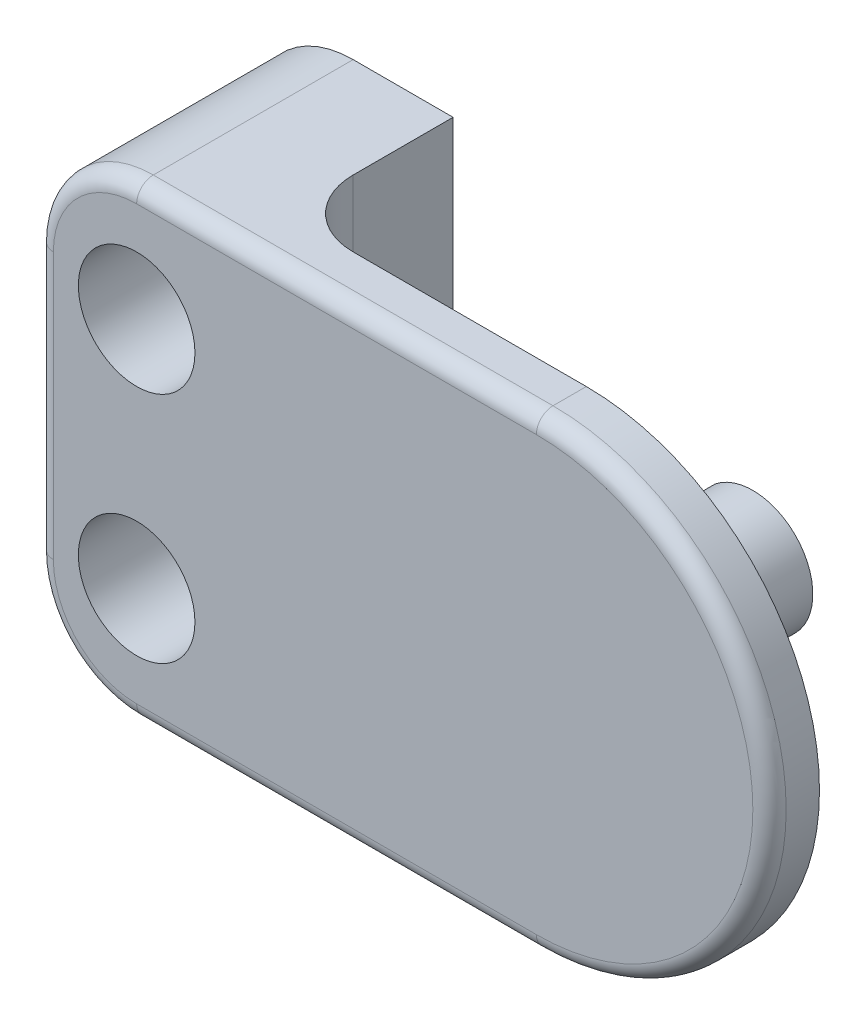
from build123d import *

# Parameters (mm, degrees)
SKETCH1_R           = 1.1
BOSS_EXTRUDE1_DEPTH = 1.5
SKETCH2_R           = 2.5
BOSS_EXTRUDE2_DEPTH = 1
BOSS_EXTRUDE3_DEPTH = 4
SKETCH4_W           = 6
SKETCH4_H           = 14
SKETCH4_R           = 1.1
BOSS_EXTRUDE4_DEPTH = 5
FILLET4_R           = 3
FILLET1_R           = 0.5
SKETCH5_R           = 1.75
CUT_EXTRUDE1_DEPTH  = 4
FILLET3_R           = 2


with BuildPart() as part:
    # Sketch1 → Boss-Extrude1 (new body)
    with BuildSketch(Plane.XY):
        with BuildLine():
            Line((-15, 7), (0, 7))
            ThreePointArc((0, 7), (7, 0), (0, -7))
            Line((0, -7), (-15, -7))
            Line((-15, -7), (-15, 7))
        make_face()
        with Locations((-12, 3.5)):
            Circle(SKETCH1_R, mode=Mode.SUBTRACT)
        with Locations((-12, -3.5)):
            Circle(SKETCH1_R, mode=Mode.SUBTRACT)
    extrude(amount=BOSS_EXTRUDE1_DEPTH)

    # Sketch2 → Boss-Extrude2 (add)
    with BuildSketch(Plane(origin=(0, 0, 0), x_dir=(-1, 0, 0), z_dir=(0, 0, -1))):
        Circle(SKETCH2_R)
    extrude(amount=BOSS_EXTRUDE2_DEPTH)

    # Sketch3 → Boss-Extrude3 (add)
    with BuildSketch(Plane(origin=(0, 0, -1), x_dir=(-1, 0, 0), z_dir=(0, 0, -1))):
        with BuildLine():
            Line((1.13862177, 1.394109201), (1.13862177, -1.394109201))
            ThreePointArc((1.13862177, -1.394109201), (-1.8, 0), (1.13862177, 1.394109201))
        make_face()
    extrude(amount=BOSS_EXTRUDE3_DEPTH)

    # Sketch4 → Boss-Extrude4 (add)
    with BuildSketch(Plane(origin=(0, 0, 0), x_dir=(-1, 0, 0), z_dir=(0, 0, -1))):
        with Locations((12, 0)):
            Rectangle(SKETCH4_W, SKETCH4_H)
        with Locations((12, 3.5)):
            Circle(SKETCH4_R, mode=Mode.SUBTRACT)
        with Locations((12, -3.5)):
            Circle(SKETCH4_R, mode=Mode.SUBTRACT)
    extrude(amount=BOSS_EXTRUDE4_DEPTH)

    # Fillet4
    fillet4_edges = [part.edges().sort_by_distance(p)[0] for p in [
        (-15, -7, -1.75),
        (-15, 7, -1.75),
    ]]
    fillet(fillet4_edges, radius=FILLET4_R)

    # Fillet1
    fillet1_edges = [part.edges().sort_by_distance(p)[0] for p in [
        (7, 0, 1.5),
        (-15, 0, 1.5),
        (-6, -7, 1.5),
        (-14.121320344, -6.121320344, 1.5),
        (-14.121320344, 6.121320344, 1.5),
        (-6, 7, 1.5),
    ]]
    fillet(fillet1_edges, radius=FILLET1_R)

    # Sketch5 → Cut-Extrude1 (cut)
    with BuildSketch(Plane.XY.offset(1.5)):
        with Locations((-12, 3.5)):
            Circle(SKETCH5_R)
        with Locations((-12, -3.5)):
            Circle(SKETCH5_R)
    extrude(amount=-CUT_EXTRUDE1_DEPTH, mode=Mode.SUBTRACT)

    # Fillet3
    fillet3_edges = [part.edges().sort_by_distance(p)[0] for p in [
        (-9, 0, 0),
    ]]
    fillet(fillet3_edges, radius=FILLET3_R)


solid = part.part
